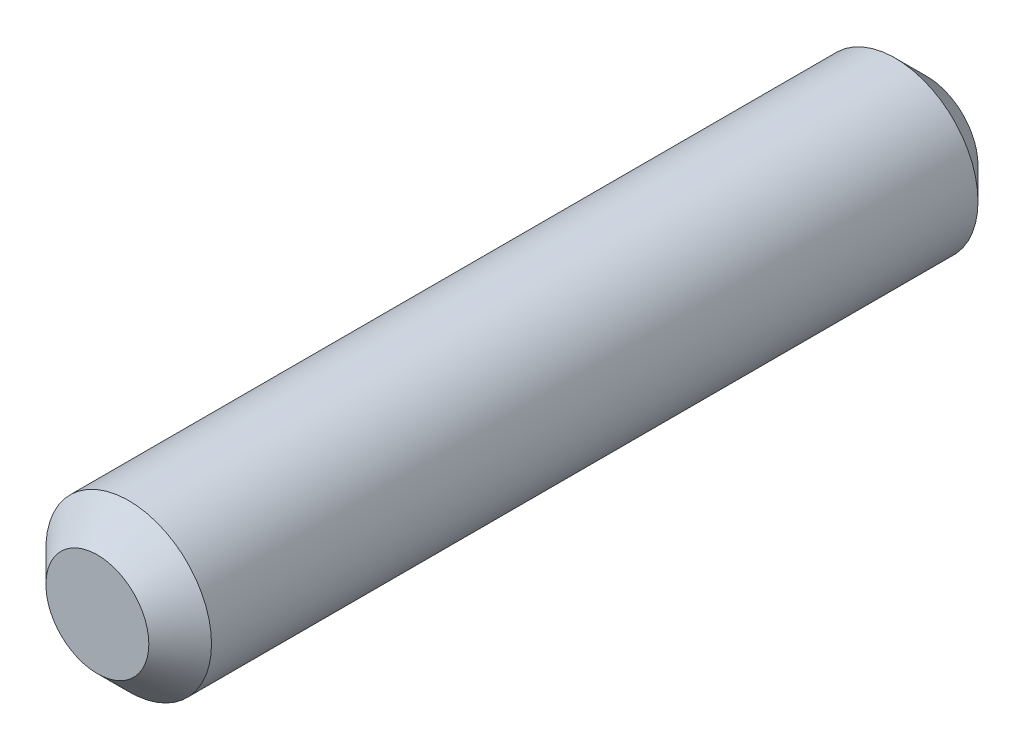
from build123d import *

# Parameters (mm, degrees)
SKETCH1_R           = 1.585
BOSS_EXTRUDE1_DEPTH = 7.935
CHAMFER1_SIZE       = 0.6


with BuildPart() as part:
    # Sketch1 → Boss-Extrude1 (new body, symmetric)
    with BuildSketch(Plane.XY):
        Circle(SKETCH1_R)
    extrude(amount=BOSS_EXTRUDE1_DEPTH, both=True)

    # Chamfer1
    chamfer1_edges = [part.edges().sort_by_distance(p)[0] for p in [
        (-1.585, 0, -7.935),
        (-1.585, 0, 7.935),
    ]]
    chamfer(chamfer1_edges, length=CHAMFER1_SIZE)


solid = part.part
